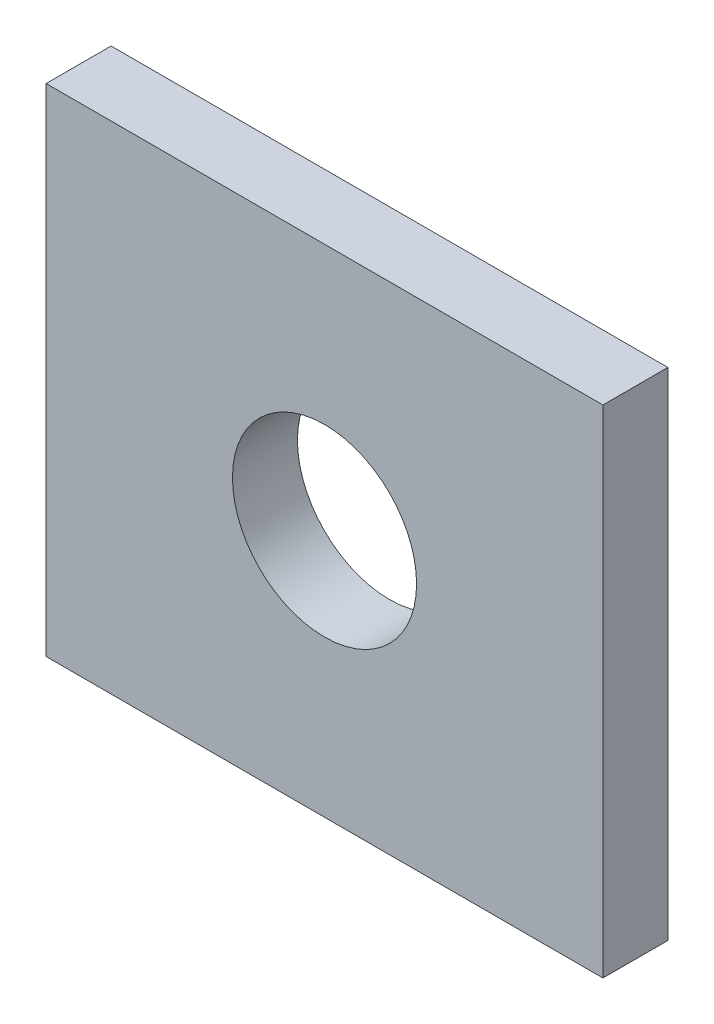
from build123d import *

# Parameters (mm, degrees)
SKETCH1_W           = 54
SKETCH1_H           = 48.13
BOSS_EXTRUDE1_DEPTH = 6.3
SKETCH2_R           = 8.9281
CUT_EXTRUDE1_DEPTH  = 7.3


with BuildPart() as part:
    # Sketch1 → Boss-Extrude1 (new body)
    with BuildSketch(Plane.XY):
        with Locations((27, 24.065)):
            Rectangle(SKETCH1_W, SKETCH1_H)
    extrude(amount=BOSS_EXTRUDE1_DEPTH)

    # Sketch2 → Cut-Extrude1 (cut, through all)
    with BuildSketch(Plane.XY.offset(6.3)):
        with Locations((27, 24.065)):
            Circle(SKETCH2_R)
    extrude(amount=-CUT_EXTRUDE1_DEPTH, mode=Mode.SUBTRACT)


solid = part.part
